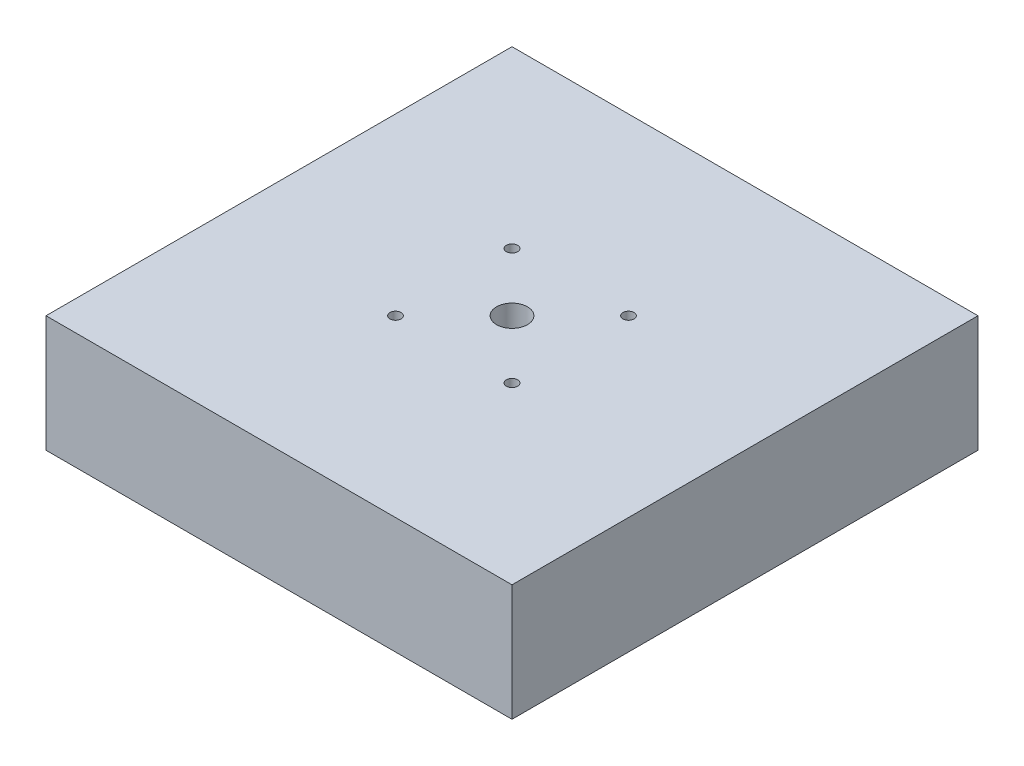
from build123d import *

# Parameters (mm, degrees)
SKETCH1_W               = 101.6
SKETCH1_H               = 101.6
BOSS_EXTRUDE1_DEPTH     = 25.4
F_1_4_CLEARANCE_HOLE1_D = 6.7564
F_2_CLEARANCE_HOLE1_D   = 2.4384
F_2_CLEARANCE_HOLE2_D   = 2.4384


with BuildPart() as part:
    # Sketch1 → Boss-Extrude1 (new body)
    with BuildSketch(Plane(origin=(0, 0, 0), x_dir=(1, 0, 0), z_dir=(0, 1, 0))):
        Rectangle(SKETCH1_W, SKETCH1_H)
    extrude(amount=BOSS_EXTRUDE1_DEPTH)

    # 1/4 Clearance Hole1 (through all)
    with Locations(Plane(origin=(0, 25.4, 0), x_dir=(1, 0, 0), z_dir=(0, 1, 0))):
        with Locations((0, 0)):
            Hole(F_1_4_CLEARANCE_HOLE1_D / 2)

    # #2 Clearance Hole1 (through all)
    with Locations(Plane(origin=(0, 25.4, 0), x_dir=(1, 0, 0), z_dir=(0, 1, 0))):
        with Locations((-12.7, 12.7), (0, 0)):
            Hole(F_2_CLEARANCE_HOLE1_D / 2)

    # #2 Clearance Hole2 (through all)
    with Locations(Plane(origin=(0, 25.4, 0), x_dir=(1, 0, 0), z_dir=(0, 1, 0))):
        with Locations((12.7, 12.7), (-12.7, -12.7), (12.7, -12.7)):
            Hole(F_2_CLEARANCE_HOLE2_D / 2)


solid = part.part
